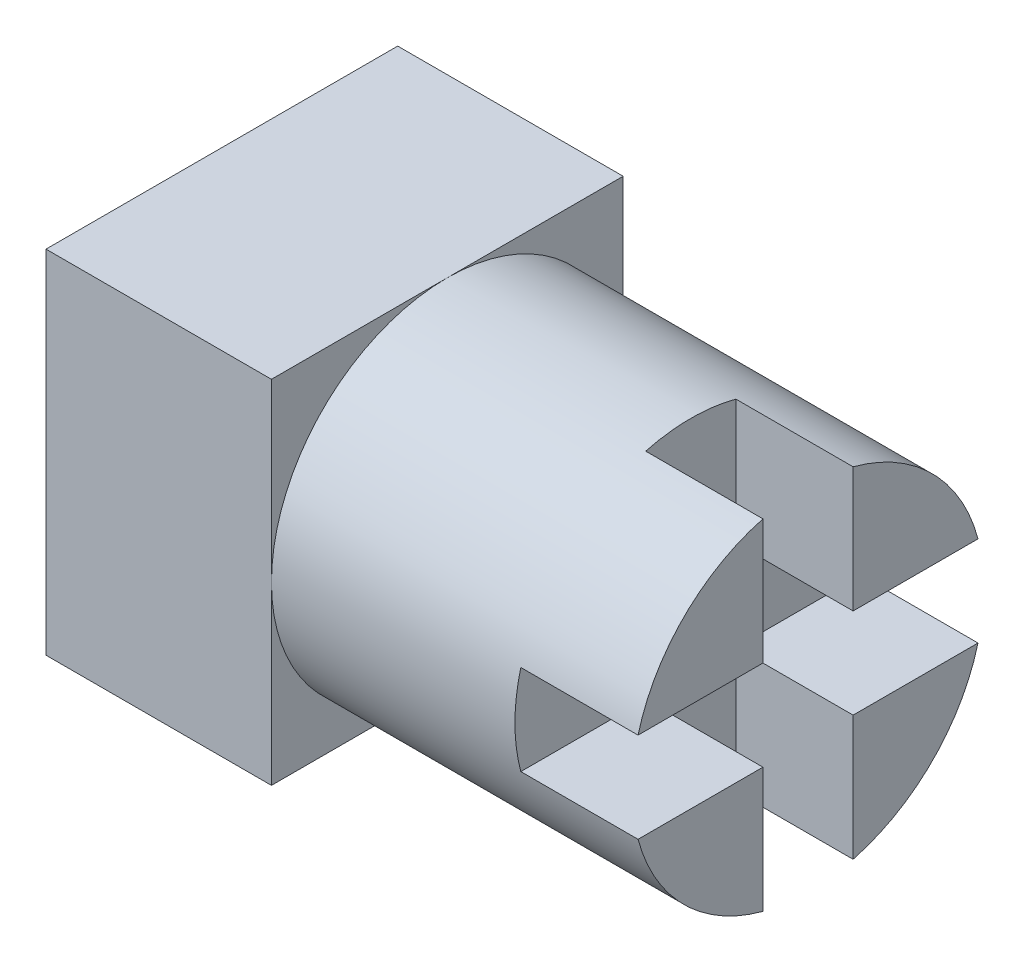
from build123d import *

# Parameters (mm, degrees)
SKETCH1_W           = 15.6
SKETCH1_H           = 15.6
BOSS_EXTRUDE1_DEPTH = 10
SKETCH2_R           = 7.8
BOSS_EXTRUDE2_DEPTH = 16
SKETCH3_W           = 4
SKETCH3_H           = 4
CUT_EXTRUDE2_DEPTH  = 5.2


with BuildPart() as part:
    # Sketch1 → Boss-Extrude1 (new body)
    with BuildSketch(Plane(origin=(0, 0, 0), x_dir=(0, 0, -1), z_dir=(1, 0, 0))):
        Rectangle(SKETCH1_W, SKETCH1_H)
    extrude(amount=BOSS_EXTRUDE1_DEPTH)

    # Sketch2 → Boss-Extrude2 (add)
    with BuildSketch(Plane(origin=(10, 0, 0), x_dir=(0, 0, -1), z_dir=(1, 0, 0))):
        Circle(SKETCH2_R)
    extrude(amount=BOSS_EXTRUDE2_DEPTH)

    # Sketch3 → Cut-Extrude2 (cut)
    with BuildSketch(Plane(origin=(26, 0, 0), x_dir=(0, 0, -1), z_dir=(1, 0, 0))):
        with BuildLine():
            Line((-2, -2), (-2, 2))
            Line((-2, 2), (-7.53923073, 2))
            ThreePointArc((-7.53923073, 2), (-7.734532943, 1.008464255), (-7.8, 0))
            ThreePointArc((-7.8, 0), (-7.734532943, -1.008464255), (-7.53923073, -2))
            Line((-7.53923073, -2), (-2, -2))
        make_face()
        with BuildLine():
            ThreePointArc((2, 7.53923073), (1.008464255, 7.734532943), (0, 7.8))
            ThreePointArc((0, 7.8), (-1.008464255, 7.734532943), (-2, 7.53923073))
            Line((-2, 7.53923073), (-2, 2))
            Line((-2, 2), (2, 2))
            Line((2, 2), (2, 7.53923073))
        make_face()
        with BuildLine():
            Line((7.53923073, 2), (2, 2))
            Line((2, 2), (2, -2))
            Line((2, -2), (7.53923073, -2))
            ThreePointArc((7.53923073, -2), (7.734532943, -1.008464255), (7.8, 0))
            ThreePointArc((7.8, 0), (7.734532943, 1.008464255), (7.53923073, 2))
        make_face()
        with BuildLine():
            Line((2, -2), (-2, -2))
            Line((-2, -2), (-2, -7.53923073))
            ThreePointArc((-2, -7.53923073), (-1.008464255, -7.734532943), (0, -7.8))
            ThreePointArc((0, -7.8), (1.008464255, -7.734532943), (2, -7.53923073))
            Line((2, -7.53923073), (2, -2))
        make_face()
        with BuildLine():
            ThreePointArc((-7.53923073, -2), (-7.734532943, -1.008464255), (-7.8, 0))
            Line((-7.8, 0), (-7.8, -2))
            Line((-7.8, -2), (-7.53923073, -2))
        make_face()
        with BuildLine():
            ThreePointArc((-7.8, 0), (-7.734532943, 1.008464255), (-7.53923073, 2))
            Line((-7.53923073, 2), (-7.8, 2))
            Line((-7.8, 2), (-7.8, 0))
        make_face()
        with BuildLine():
            Line((0, 7.8), (-2, 7.8))
            Line((-2, 7.8), (-2, 7.53923073))
            ThreePointArc((-2, 7.53923073), (-1.008464255, 7.734532943), (0, 7.8))
        make_face()
        with BuildLine():
            Line((2, 7.8), (0, 7.8))
            ThreePointArc((0, 7.8), (1.008464255, 7.734532943), (2, 7.53923073))
            Line((2, 7.53923073), (2, 7.8))
        make_face()
        with BuildLine():
            Line((7.8, 2), (7.53923073, 2))
            ThreePointArc((7.53923073, 2), (7.734532943, 1.008464255), (7.8, 0))
            Line((7.8, 0), (7.8, 2))
        make_face()
        with BuildLine():
            Line((7.8, -2), (7.8, 0))
            ThreePointArc((7.8, 0), (7.734532943, -1.008464255), (7.53923073, -2))
            Line((7.53923073, -2), (7.8, -2))
        make_face()
        Rectangle(SKETCH3_W, SKETCH3_H)
    extrude(amount=-CUT_EXTRUDE2_DEPTH, mode=Mode.SUBTRACT)


solid = part.part
